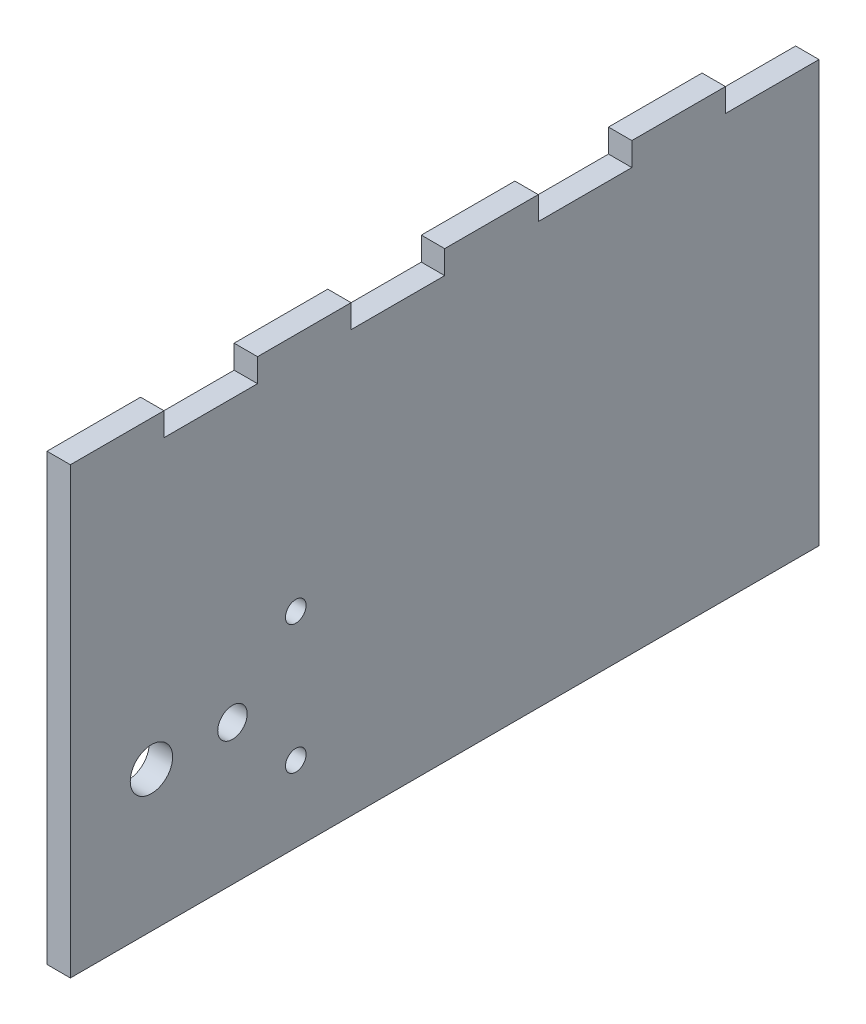
from build123d import *

# Parameters (mm, degrees)
BOSS_EXTRUDE1_DEPTH = 3.175
CUT_EXTRUDE1_REACH  = 5.175
SKETCH2_R           = 1.4
SKETCH2_R_2         = 2
SKETCH2_R_3         = 2.876999961


with BuildPart() as part:
    # Sketch1 → Boss-Extrude1 (new body)
    with BuildSketch(Plane(origin=(0, 0, 0), x_dir=(0, 0, -1), z_dir=(1, 0, 0))):
        Polygon((0, 0), (0, 60.325), (12.7, 60.325), (12.7, 57.15), (25.4, 57.15), (25.4, 60.325), (38.1, 60.325), (38.1, 57.15), (50.8, 57.15), (50.8, 60.325), (63.5, 60.325), (63.5, 57.15), (76.2, 57.15), (76.2, 60.325), (88.9, 60.325), (88.9, 57.15), (101.6, 57.15), (101.6, 0), align=None)
    extrude(amount=BOSS_EXTRUDE1_DEPTH)

    # Sketch2 → Cut-Extrude1 (cut, up to next)
    with BuildSketch(Plane(origin=(3.175, 0, 0), x_dir=(0, 0, -1), z_dir=(1, 0, 0)), mode=Mode.PRIVATE) as cut_extrude1_sk1:
        with Locations((30.59102, 10.3)):
            Circle(SKETCH2_R)
    cut_extrude1_tool1 = extrude(cut_extrude1_sk1.sketch, amount=-CUT_EXTRUDE1_REACH, mode=Mode.PRIVATE) & part.part
    add(cut_extrude1_tool1.solids().sort_by_distance((3.175, 10.3, -30.59102))[0], mode=Mode.SUBTRACT)
    # Sketch2 → Cut-Extrude1 (cut, up to next)
    with BuildSketch(Plane(origin=(3.175, 0, 0), x_dir=(0, 0, -1), z_dir=(1, 0, 0)), mode=Mode.PRIVATE) as cut_extrude1_sk2:
        with Locations((30.59102, 27.8)):
            Circle(SKETCH2_R)
    cut_extrude1_tool2 = extrude(cut_extrude1_sk2.sketch, amount=-CUT_EXTRUDE1_REACH, mode=Mode.PRIVATE) & part.part
    add(cut_extrude1_tool2.solids().sort_by_distance((3.175, 27.8, -30.59102))[0], mode=Mode.SUBTRACT)
    # Sketch2 → Cut-Extrude1 (cut, up to next)
    with BuildSketch(Plane(origin=(3.175, 0, 0), x_dir=(0, 0, -1), z_dir=(1, 0, 0)), mode=Mode.PRIVATE) as cut_extrude1_sk3:
        with Locations((22.0000034, 19.05)):
            Circle(SKETCH2_R_2)
    cut_extrude1_tool3 = extrude(cut_extrude1_sk3.sketch, amount=-CUT_EXTRUDE1_REACH, mode=Mode.PRIVATE) & part.part
    add(cut_extrude1_tool3.solids().sort_by_distance((3.175, 19.05, -22.000003))[0], mode=Mode.SUBTRACT)
    # Sketch2 → Cut-Extrude1 (cut, up to next)
    with BuildSketch(Plane(origin=(3.175, 0, 0), x_dir=(0, 0, -1), z_dir=(1, 0, 0)), mode=Mode.PRIVATE) as cut_extrude1_sk4:
        with Locations((11, 19.05)):
            Circle(SKETCH2_R_3)
    cut_extrude1_tool4 = extrude(cut_extrude1_sk4.sketch, amount=-CUT_EXTRUDE1_REACH, mode=Mode.PRIVATE) & part.part
    add(cut_extrude1_tool4.solids().sort_by_distance((3.175, 19.05, -11))[0], mode=Mode.SUBTRACT)


solid = part.part
